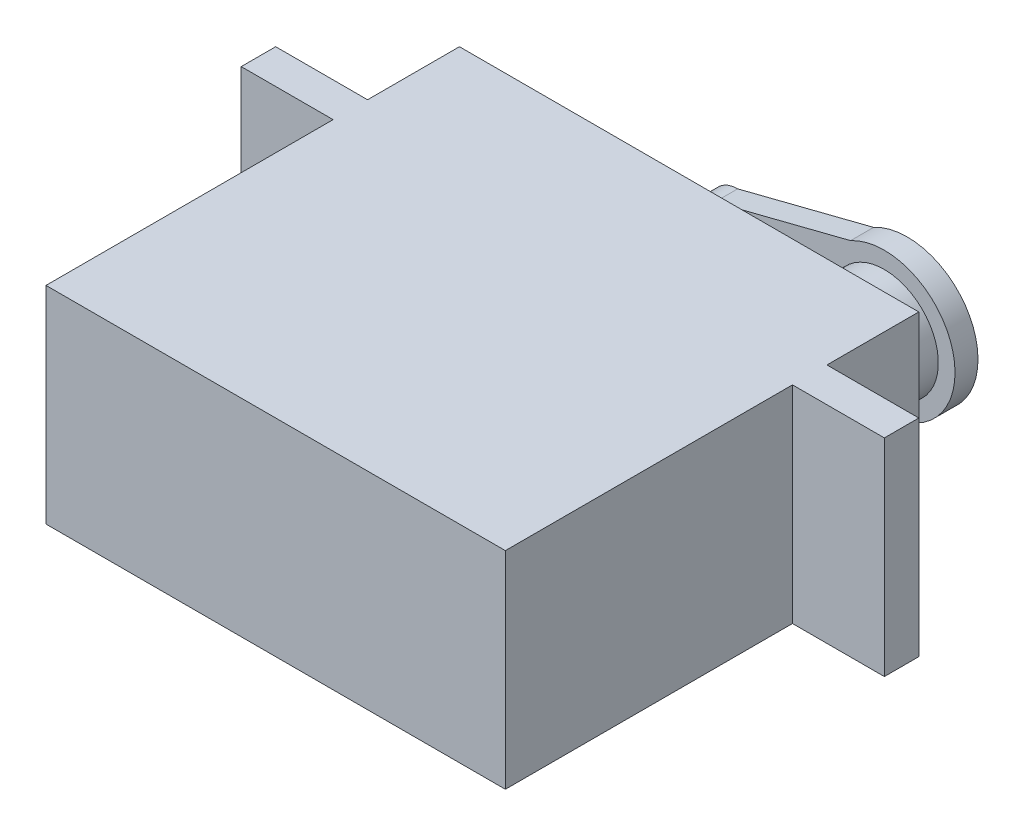
from build123d import *

# Parameters (mm, degrees)
SKETCH_1_W      = 56
SKETCH_1_H      = 18
EXTRUDE_1_DEPTH = 3
EXTRUDE_2_DEPTH = 25
EXTRUDE_3_DEPTH = 8
SKETCH_4_R      = 4.7
EXTRUDE_4_DEPTH = 6
EXTRUDE_5_DEPTH = 2


with BuildPart() as part:
    # Эскиз1 → Бобышка-Вытянуть1 (new body)
    with BuildSketch(Plane.XY):
        with Locations((-28, 9)):
            Rectangle(SKETCH_1_W, SKETCH_1_H)
    extrude(amount=EXTRUDE_1_DEPTH)

    # Эскиз2 → Бобышка-Вытянуть2 (add)
    with BuildSketch(Plane.XY.offset(3)):
        Polygon((-28, 18), (-48, 18), (-48, 0), (-8, 0), (-8, 18), align=None)
    extrude(amount=EXTRUDE_2_DEPTH)

    # Эскиз3 → Бобышка-Вытянуть3 (add)
    with BuildSketch(Plane(origin=(0, 0, 0), x_dir=(-1, 0, 0), z_dir=(0, 0, -1))):
        Polygon((48, 18), (28, 18), (8, 18), (8, 0), (48, 0), align=None)
    extrude(amount=EXTRUDE_3_DEPTH)

    # Эскиз4 → Бобышка-Вытянуть4 (add)
    with BuildSketch(Plane(origin=(0, 0, -8), x_dir=(-1, 0, 0), z_dir=(0, 0, -1))):
        with Locations((17, 9)):
            Circle(SKETCH_4_R)
    extrude(amount=EXTRUDE_4_DEPTH)

    # Эскиз5 → Бобышка-Вытянуть5 (add)
    with BuildSketch(Plane(origin=(0, 0, -14), x_dir=(-1, 0, 0), z_dir=(0, 0, -1))):
        with BuildLine():
            Line((19.941294174, 14.406291264), (31.770292026, 11.396788075))
            ThreePointArc((31.770292026, 11.396788075), (34.167080101, 9), (31.770292026, 6.603211925))
            Line((31.770292026, 6.603211925), (19.941294174, 3.593708736))
            ThreePointArc((19.941294174, 3.593708736), (10.845392243, 9), (19.941294174, 14.406291264))
        make_face()
    extrude(amount=EXTRUDE_5_DEPTH)


solid = part.part
